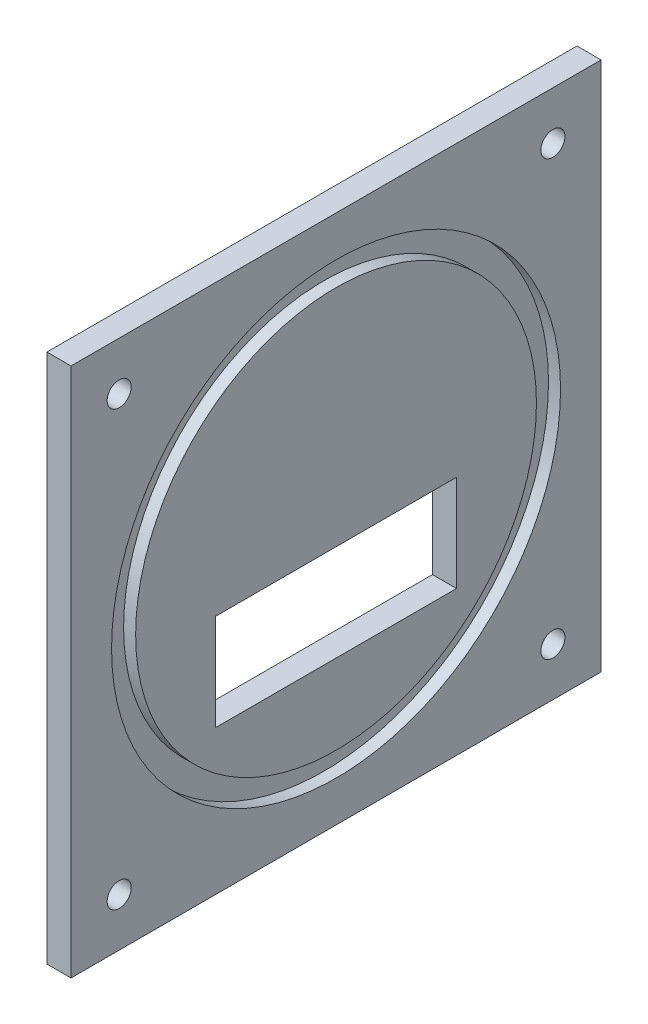
from build123d import *

# Parameters (mm, degrees)
SKETCH1_W           = 220
SKETCH1_H           = 220
SKETCH1_W_2         = 100
SKETCH1_H_2         = 40
BOSS_EXTRUDE1_DEPTH = 10
SKETCH2_R           = 93.17284
SKETCH2_R_2         = 83.17284
CUT_EXTRUDE1_DEPTH  = 5
SKETCH3_R           = 5
CUT_EXTRUDE2_DEPTH  = 11


with BuildPart() as part:
    # Sketch1 → Boss-Extrude1 (new body)
    with BuildSketch(Plane(origin=(0, 0, 0), x_dir=(0, 0, -1), z_dir=(1, 0, 0))):
        with Locations((110, 110)):
            Rectangle(SKETCH1_W, SKETCH1_H)
        with Locations((110, 80)):
            Rectangle(SKETCH1_W_2, SKETCH1_H_2, mode=Mode.SUBTRACT)
    extrude(amount=BOSS_EXTRUDE1_DEPTH)

    # Sketch2 → Cut-Extrude1 (cut)
    with BuildSketch(Plane(origin=(10, 0, 0), x_dir=(0, 0, -1), z_dir=(1, 0, 0))):
        with Locations((110, 110)):
            Circle(SKETCH2_R)
        with Locations((110, 110)):
            Circle(SKETCH2_R_2, mode=Mode.SUBTRACT)
    extrude(amount=-CUT_EXTRUDE1_DEPTH, mode=Mode.SUBTRACT)

    # Sketch3 → Cut-Extrude2 (cut, through all)
    with BuildSketch(Plane(origin=(10, 0, 0), x_dir=(0, 0, -1), z_dir=(1, 0, 0))):
        with Locations((20, 200)):
            Circle(SKETCH3_R)
        with Locations((200, 200)):
            Circle(SKETCH3_R)
        with Locations((200, 20)):
            Circle(SKETCH3_R)
        with Locations((20, 20)):
            Circle(SKETCH3_R)
    extrude(amount=-CUT_EXTRUDE2_DEPTH, mode=Mode.SUBTRACT)


solid = part.part
